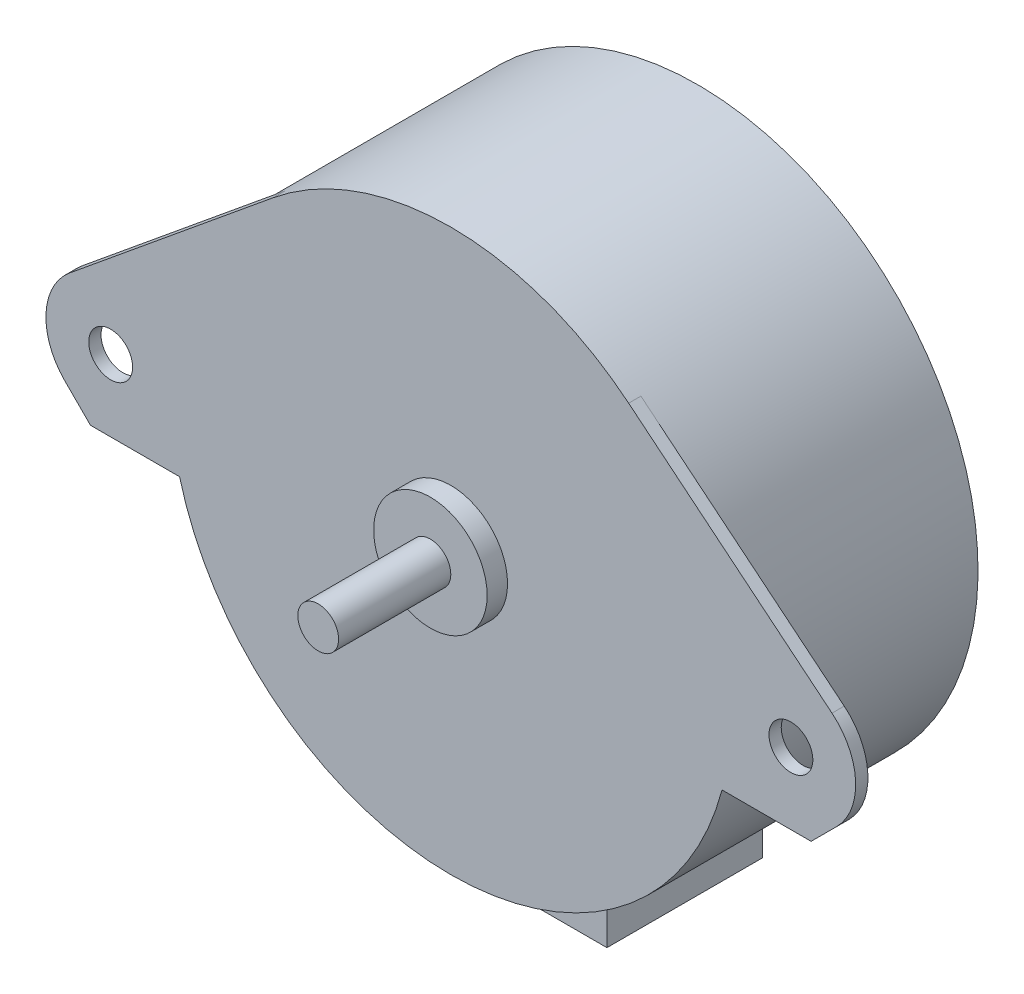
from build123d import *

# Parameters (mm, degrees)
SKETCH2_R           = 2.15
SKETCH2_R_2         = 5.565
BOSS_EXTRUDE1_DEPTH = 1.2
SKETCH3_W           = 12.7
SKETCH3_H           = 15.24
BOSS_EXTRUDE2_DEPTH = 35


with BuildPart() as part:
    # Sketch1 → Revolve1 (revolve)
    with BuildSketch(Plane(origin=(0, 0, 0), x_dir=(0, 0, -1), z_dir=(1, 0, 0))):
        Polygon((0, 0), (0, 2), (-1, 2), (-1, 27.5), (-24, 27.5), (-24, 5.565), (-27.2, 5.565), (-27.2, 2), (-38.2, 2), (-38.2, 0), align=None)
    revolve(axis=Axis((0, 0, 38.2), (0, 0, -1)))

    # Sketch2 → Boss-Extrude1 (add)
    with BuildSketch(Plane.XY.offset(24)):
        with BuildLine():
            Line((-17.440029985, 21.262534048), (-37.377061469, 4.909712407))
            ThreePointArc((-37.377061469, 4.909712407), (-39.692308695, 0.312442672), (-37.840128061, -4.490128061))
            Line((-37.840128061, -4.490128061), (-35.330256121, -7))
            Line((-35.330256121, -7), (-26.594172294, -7))
            ThreePointArc((-26.594172294, -7), (0, -27.5), (26.594172294, -7))
            Line((26.594172294, -7), (35.330256121, -7))
            Line((35.330256121, -7), (37.840128061, -4.490128061))
            ThreePointArc((37.840128061, -4.490128061), (39.692308695, 0.312442672), (37.377061469, 4.909712407))
            Line((37.377061469, 4.909712407), (17.440029985, 21.262534048))
            ThreePointArc((17.440029985, 21.262534048), (0, 27.5), (-17.440029985, 21.262534048))
        make_face()
        with Locations((-33.35, 0)):
            Circle(SKETCH2_R, mode=Mode.SUBTRACT)
        with Locations((33.35, 0)):
            Circle(SKETCH2_R, mode=Mode.SUBTRACT)
        Circle(SKETCH2_R_2, mode=Mode.SUBTRACT)
    extrude(amount=BOSS_EXTRUDE1_DEPTH)

    # Sketch3 → Boss-Extrude2 (add)
    with BuildSketch(Plane(origin=(0, 0, 0), x_dir=(1, 0, 0), z_dir=(0, 1, 0))):
        with Locations((0, -8.62)):
            Rectangle(SKETCH3_W, SKETCH3_H)
    extrude(amount=-BOSS_EXTRUDE2_DEPTH)


solid = part.part
